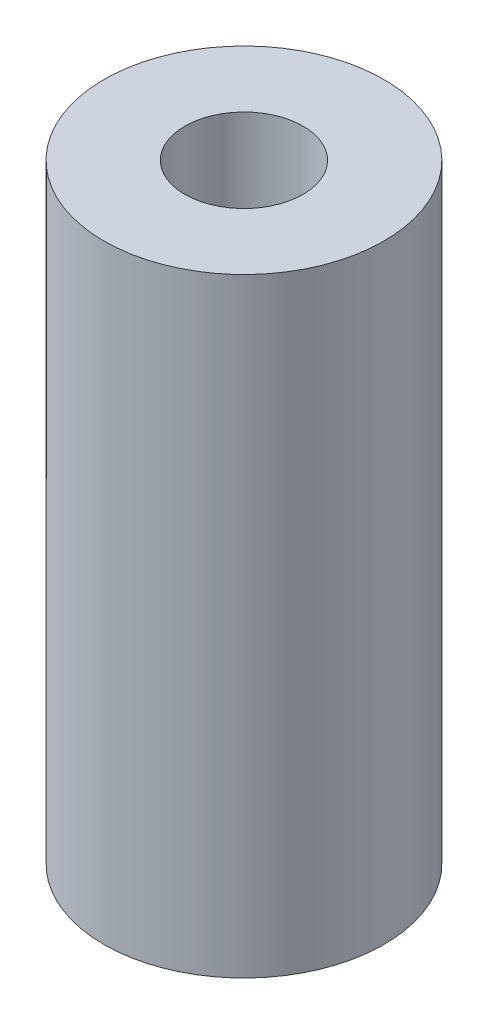
from build123d import *

# Parameters (mm, degrees)
SKETCH1_R                = 11.830004421
SKETCH1_R_2              = 5
BOSS_EXTRUDE1_DEPTH      = 45.5
BOSS_EXTRUDE1_DEPTH_BACK = 6


with BuildPart() as part:
    # Sketch1 → Boss-Extrude1 (new body, two sides)
    with BuildSketch(Plane(origin=(0, 0, 0), x_dir=(1, 0, 0), z_dir=(0, 1, 0))) as boss_extrude1_sk:
        Circle(SKETCH1_R)
        Circle(SKETCH1_R_2, mode=Mode.SUBTRACT)
    extrude(amount=BOSS_EXTRUDE1_DEPTH)
    extrude(boss_extrude1_sk.sketch, amount=-BOSS_EXTRUDE1_DEPTH_BACK)


solid = part.part
